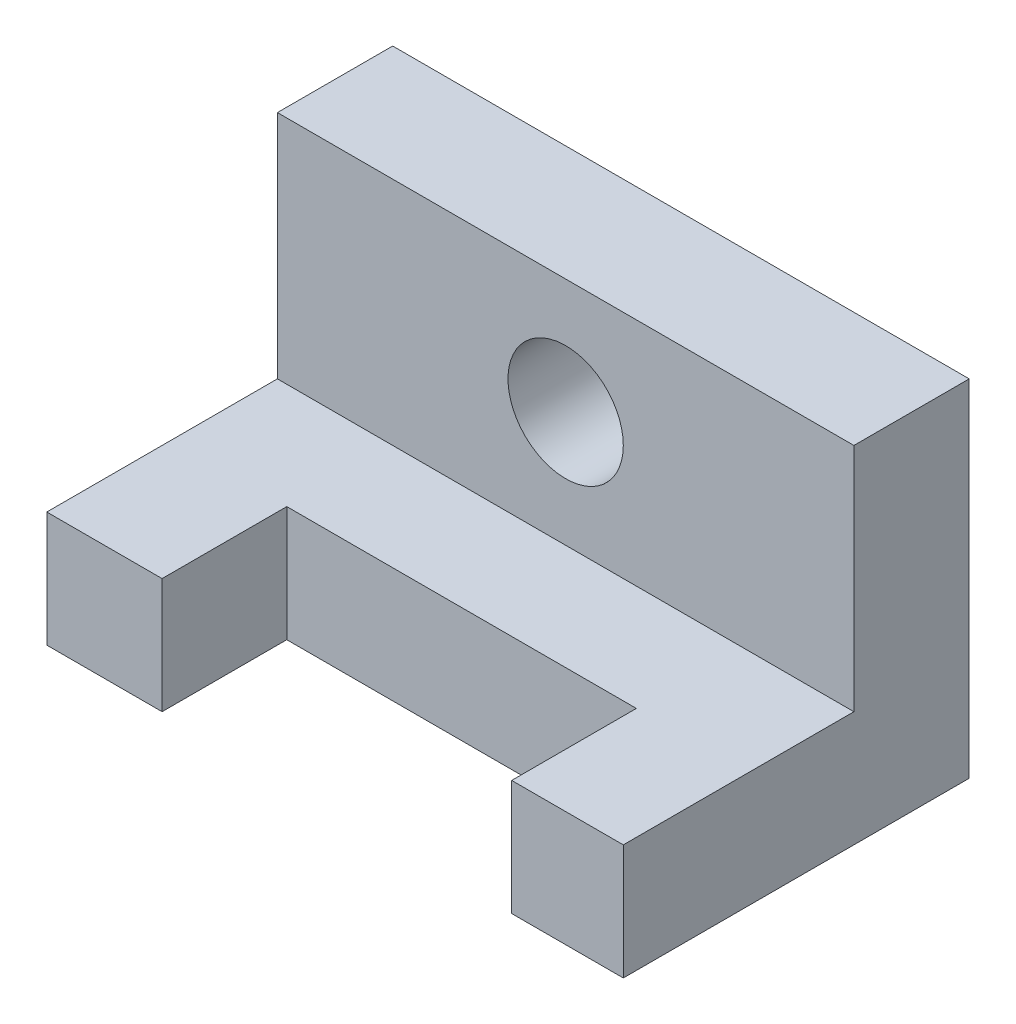
from build123d import *

# Parameters (mm, degrees)
BOSS_EXTRUDE1_DEPTH = 2540
SKETCH2_W           = 1540.234303032
SKETCH2_H           = 549.342952078
CUT_EXTRUDE1_DEPTH  = 508
SKETCH3_R           = 254
CUT_EXTRUDE2_DEPTH  = 508


with BuildPart() as part:
    # Sketch1 → Boss-Extrude1 (new body)
    with BuildSketch(Plane(origin=(0, 0, 0), x_dir=(0, 0, -1), z_dir=(1, 0, 0))):
        Polygon((0, 0), (-1524, 0), (-1524, 508), (-508, 508), (-508, 1524), (0, 1524), align=None)
    extrude(amount=BOSS_EXTRUDE1_DEPTH)

    # Sketch2 → Cut-Extrude1 (cut)
    with BuildSketch(Plane(origin=(0, 0, 0), x_dir=(1, 0, 0), z_dir=(0, 1, 0))):
        with Locations((1278.117151516, -1249.328523961)):
            Rectangle(SKETCH2_W, SKETCH2_H)
    extrude(amount=CUT_EXTRUDE1_DEPTH, mode=Mode.SUBTRACT)

    # Sketch3 → Cut-Extrude2 (cut)
    with BuildSketch(Plane.XY):
        with Locations((1270, 1016)):
            Circle(SKETCH3_R)
    extrude(amount=CUT_EXTRUDE2_DEPTH, mode=Mode.SUBTRACT)


solid = part.part
